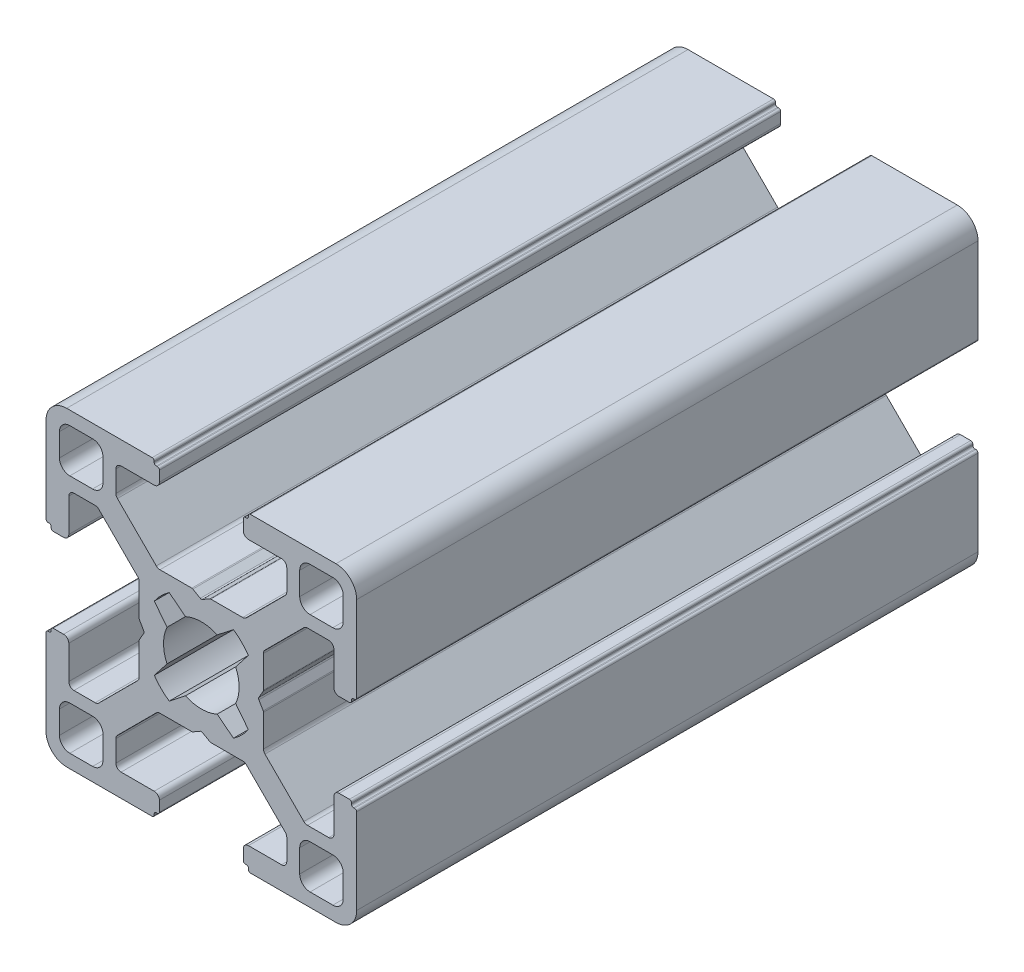
from build123d import *

# Parameters (mm, degrees)
EXTRUDE_1_DEPTH = 60


with BuildPart() as part:
    # Эскиз1 → Бобышка-Вытянуть1 (new body)
    with BuildSketch(Plane.XY):
        with BuildLine():
            Line((-5.557735027, 0.1), (-5.973205081, 0.819615242))
            ThreePointArc((-5.973205081, 0.819615242), (-5.993185165, 0.867851433), (-6, 0.919615242))
            Line((-6, 0.919615242), (-6, 3.996841995))
            ThreePointArc((-6, 3.996841995), (-6.038060234, 4.188183711), (-6.146446609, 4.350395385))
            Line((-6.146446609, 4.350395385), (-9.899604615, 8.103553391))
            ThreePointArc((-9.899604615, 8.103553391), (-10.061816289, 8.211939766), (-10.253158005, 8.25))
            Line((-10.253158005, 8.25), (-12.3, 8.25))
            ThreePointArc((-12.3, 8.25), (-12.653553391, 8.103553391), (-12.8, 7.75))
            Line((-12.8, 7.75), (-12.8, 4.55))
            ThreePointArc((-12.8, 4.55), (-12.946446609, 4.196446609), (-13.3, 4.05))
            Line((-13.3, 4.05), (-14.3, 4.05))
            ThreePointArc((-14.3, 4.05), (-14.441421356, 4.108578644), (-14.5, 4.25))
            Line((-14.5, 4.25), (-14.5, 4.35))
            ThreePointArc((-14.5, 4.35), (-14.558578644, 4.491421356), (-14.7, 4.55))
            Line((-14.7, 4.55), (-14.8, 4.55))
            ThreePointArc((-14.8, 4.55), (-14.941421356, 4.608578644), (-15, 4.75))
            Line((-15, 4.75), (-15, 13))
            ThreePointArc((-15, 13), (-14.414213562, 14.414213562), (-13, 15))
            Line((-13, 15), (-4.75, 15))
            ThreePointArc((-4.75, 15), (-4.608578644, 14.941421356), (-4.55, 14.8))
            Line((-4.55, 14.8), (-4.55, 14.7))
            ThreePointArc((-4.55, 14.7), (-4.491421356, 14.558578644), (-4.35, 14.5))
            Line((-4.35, 14.5), (-4.25, 14.5))
            ThreePointArc((-4.25, 14.5), (-4.108578644, 14.441421356), (-4.05, 14.3))
            Line((-4.05, 14.3), (-4.05, 13.3))
            ThreePointArc((-4.05, 13.3), (-4.196446609, 12.946446609), (-4.55, 12.8))
            Line((-4.55, 12.8), (-7.75, 12.8))
            ThreePointArc((-7.75, 12.8), (-8.103553391, 12.653553391), (-8.25, 12.3))
            Line((-8.25, 12.3), (-8.25, 10.253158005))
            ThreePointArc((-8.25, 10.253158005), (-8.211939766, 10.061816289), (-8.103553391, 9.899604615))
            Line((-8.103553391, 9.899604615), (-4.350395385, 6.146446609))
            ThreePointArc((-4.350395385, 6.146446609), (-4.188183711, 6.038060234), (-3.996841995, 6))
            Line((-3.996841995, 6), (-0.919615242, 6))
            ThreePointArc((-0.919615242, 6), (-0.867851433, 5.993185165), (-0.819615242, 5.973205081))
            Line((-0.819615242, 5.973205081), (-0.1, 5.557735027))
            ThreePointArc((-0.1, 5.557735027), (0, 5.530940108), (0.1, 5.557735027))
            Line((0.1, 5.557735027), (0.819615242, 5.973205081))
            ThreePointArc((0.819615242, 5.973205081), (0.867851433, 5.993185165), (0.919615242, 6))
            Line((0.919615242, 6), (3.996841995, 6))
            ThreePointArc((3.996841995, 6), (4.188183711, 6.038060234), (4.350395385, 6.146446609))
            Line((4.350395385, 6.146446609), (8.103553391, 9.899604615))
            ThreePointArc((8.103553391, 9.899604615), (8.211939766, 10.061816289), (8.25, 10.253158005))
            Line((8.25, 10.253158005), (8.25, 12.3))
            ThreePointArc((8.25, 12.3), (8.103553391, 12.653553391), (7.75, 12.8))
            Line((7.75, 12.8), (4.55, 12.8))
            ThreePointArc((4.55, 12.8), (4.196446609, 12.946446609), (4.05, 13.3))
            Line((4.05, 13.3), (4.05, 14.3))
            ThreePointArc((4.05, 14.3), (4.108578644, 14.441421356), (4.25, 14.5))
            Line((4.25, 14.5), (4.35, 14.5))
            ThreePointArc((4.35, 14.5), (4.491421356, 14.558578644), (4.55, 14.7))
            Line((4.55, 14.7), (4.55, 14.8))
            ThreePointArc((4.55, 14.8), (4.608578644, 14.941421356), (4.75, 15))
            Line((4.75, 15), (13, 15))
            ThreePointArc((13, 15), (14.414213562, 14.414213562), (15, 13))
            Line((15, 13), (15, 4.75))
            ThreePointArc((15, 4.75), (14.941421356, 4.608578644), (14.8, 4.55))
            Line((14.8, 4.55), (14.7, 4.55))
            ThreePointArc((14.7, 4.55), (14.558578644, 4.491421356), (14.5, 4.35))
            Line((14.5, 4.35), (14.5, 4.25))
            ThreePointArc((14.5, 4.25), (14.441421356, 4.108578644), (14.3, 4.05))
            Line((14.3, 4.05), (13.3, 4.05))
            ThreePointArc((13.3, 4.05), (12.946446609, 4.196446609), (12.8, 4.55))
            Line((12.8, 4.55), (12.8, 7.75))
            ThreePointArc((12.8, 7.75), (12.653553391, 8.103553391), (12.3, 8.25))
            Line((12.3, 8.25), (10.253158005, 8.25))
            ThreePointArc((10.253158005, 8.25), (10.061816289, 8.211939766), (9.899604615, 8.103553391))
            Line((9.899604615, 8.103553391), (6.146446609, 4.350395385))
            ThreePointArc((6.146446609, 4.350395385), (6.038060234, 4.188183711), (6, 3.996841995))
            Line((6, 3.996841995), (6, 0.919615242))
            ThreePointArc((6, 0.919615242), (5.993185165, 0.867851433), (5.973205081, 0.819615242))
            Line((5.973205081, 0.819615242), (5.557735027, 0.1))
            ThreePointArc((5.557735027, 0.1), (5.530940108, 0), (5.557735027, -0.1))
            Line((5.557735027, -0.1), (5.973205081, -0.819615242))
            ThreePointArc((5.973205081, -0.819615242), (5.993185165, -0.867851433), (6, -0.919615242))
            Line((6, -0.919615242), (6, -3.996841995))
            ThreePointArc((6, -3.996841995), (6.038060234, -4.188183711), (6.146446609, -4.350395385))
            Line((6.146446609, -4.350395385), (9.899604615, -8.103553391))
            ThreePointArc((9.899604615, -8.103553391), (10.061816289, -8.211939766), (10.253158005, -8.25))
            Line((10.253158005, -8.25), (12.3, -8.25))
            ThreePointArc((12.3, -8.25), (12.653553391, -8.103553391), (12.8, -7.75))
            Line((12.8, -7.75), (12.8, -4.55))
            ThreePointArc((12.8, -4.55), (12.946446609, -4.196446609), (13.3, -4.05))
            Line((13.3, -4.05), (14.3, -4.05))
            ThreePointArc((14.3, -4.05), (14.441421356, -4.108578644), (14.5, -4.25))
            Line((14.5, -4.25), (14.5, -4.35))
            ThreePointArc((14.5, -4.35), (14.558578644, -4.491421356), (14.7, -4.55))
            Line((14.7, -4.55), (14.8, -4.55))
            ThreePointArc((14.8, -4.55), (14.941421356, -4.608578644), (15, -4.75))
            Line((15, -4.75), (15, -13))
            ThreePointArc((15, -13), (14.414213562, -14.414213562), (13, -15))
            Line((13, -15), (4.75, -15))
            ThreePointArc((4.75, -15), (4.608578644, -14.941421356), (4.55, -14.8))
            Line((4.55, -14.8), (4.55, -14.7))
            ThreePointArc((4.55, -14.7), (4.491421356, -14.558578644), (4.35, -14.5))
            Line((4.35, -14.5), (4.25, -14.5))
            ThreePointArc((4.25, -14.5), (4.108578644, -14.441421356), (4.05, -14.3))
            Line((4.05, -14.3), (4.05, -13.3))
            ThreePointArc((4.05, -13.3), (4.196446609, -12.946446609), (4.55, -12.8))
            Line((4.55, -12.8), (7.75, -12.8))
            ThreePointArc((7.75, -12.8), (8.103553391, -12.653553391), (8.25, -12.3))
            Line((8.25, -12.3), (8.25, -10.253158005))
            ThreePointArc((8.25, -10.253158005), (8.211939766, -10.061816289), (8.103553391, -9.899604615))
            Line((8.103553391, -9.899604615), (4.350395385, -6.146446609))
            ThreePointArc((4.350395385, -6.146446609), (4.188183711, -6.038060234), (3.996841995, -6))
            Line((3.996841995, -6), (0.919615242, -6))
            ThreePointArc((0.919615242, -6), (0.867851433, -5.993185165), (0.819615242, -5.973205081))
            Line((0.819615242, -5.973205081), (0.1, -5.557735027))
            ThreePointArc((0.1, -5.557735027), (0, -5.530940108), (-0.1, -5.557735027))
            Line((-0.1, -5.557735027), (-0.819615242, -5.973205081))
            ThreePointArc((-0.819615242, -5.973205081), (-0.867851433, -5.993185165), (-0.919615242, -6))
            Line((-0.919615242, -6), (-3.996841995, -6))
            ThreePointArc((-3.996841995, -6), (-4.188183711, -6.038060234), (-4.350395385, -6.146446609))
            Line((-4.350395385, -6.146446609), (-8.103553391, -9.899604615))
            ThreePointArc((-8.103553391, -9.899604615), (-8.211939766, -10.061816289), (-8.25, -10.253158005))
            Line((-8.25, -10.253158005), (-8.25, -12.3))
            ThreePointArc((-8.25, -12.3), (-8.103553391, -12.653553391), (-7.75, -12.8))
            Line((-7.75, -12.8), (-4.55, -12.8))
            ThreePointArc((-4.55, -12.8), (-4.196446609, -12.946446609), (-4.05, -13.3))
            Line((-4.05, -13.3), (-4.05, -14.3))
            ThreePointArc((-4.05, -14.3), (-4.108578644, -14.441421356), (-4.25, -14.5))
            Line((-4.25, -14.5), (-4.35, -14.5))
            ThreePointArc((-4.35, -14.5), (-4.491421356, -14.558578644), (-4.55, -14.7))
            Line((-4.55, -14.7), (-4.55, -14.8))
            ThreePointArc((-4.55, -14.8), (-4.608578644, -14.941421356), (-4.75, -15))
            Line((-4.75, -15), (-13, -15))
            ThreePointArc((-13, -15), (-14.414213562, -14.414213562), (-15, -13))
            Line((-15, -13), (-15, -4.75))
            ThreePointArc((-15, -4.75), (-14.941421356, -4.608578644), (-14.8, -4.55))
            Line((-14.8, -4.55), (-14.7, -4.55))
            ThreePointArc((-14.7, -4.55), (-14.558578644, -4.491421356), (-14.5, -4.35))
            Line((-14.5, -4.35), (-14.5, -4.25))
            ThreePointArc((-14.5, -4.25), (-14.441421356, -4.108578644), (-14.3, -4.05))
            Line((-14.3, -4.05), (-13.3, -4.05))
            ThreePointArc((-13.3, -4.05), (-12.946446609, -4.196446609), (-12.8, -4.55))
            Line((-12.8, -4.55), (-12.8, -7.75))
            ThreePointArc((-12.8, -7.75), (-12.653553391, -8.103553391), (-12.3, -8.25))
            Line((-12.3, -8.25), (-10.253158005, -8.25))
            ThreePointArc((-10.253158005, -8.25), (-10.061816289, -8.211939766), (-9.899604615, -8.103553391))
            Line((-9.899604615, -8.103553391), (-6.146446609, -4.350395385))
            ThreePointArc((-6.146446609, -4.350395385), (-6.038060234, -4.188183711), (-6, -3.996841995))
            Line((-6, -3.996841995), (-6, -0.919615242))
            ThreePointArc((-6, -0.919615242), (-5.993185165, -0.867851433), (-5.973205081, -0.819615242))
            Line((-5.973205081, -0.819615242), (-5.557735027, -0.1))
            ThreePointArc((-5.557735027, -0.1), (-5.530940108, 0), (-5.557735027, 0.1))
        make_face()
        with BuildLine():
            Line((-4.54098589, 3.103135052), (-3.313131952, 1.531553678))
            ThreePointArc((-3.313131952, 1.531553678), (-3.65, 0), (-3.313131952, -1.531553678))
            Line((-3.313131952, -1.531553678), (-4.54098589, -3.103135052))
            ThreePointArc((-4.54098589, -3.103135052), (-3.889087297, -3.889087297), (-3.103135052, -4.54098589))
            Line((-3.103135052, -4.54098589), (-1.531553678, -3.313131952))
            ThreePointArc((-1.531553678, -3.313131952), (0, -3.65), (1.531553678, -3.313131952))
            Line((1.531553678, -3.313131952), (3.103135052, -4.54098589))
            ThreePointArc((3.103135052, -4.54098589), (3.889087297, -3.889087297), (4.54098589, -3.103135052))
            Line((4.54098589, -3.103135052), (3.313131952, -1.531553678))
            ThreePointArc((3.313131952, -1.531553678), (3.65, 0), (3.313131952, 1.531553678))
            Line((3.313131952, 1.531553678), (4.54098589, 3.103135052))
            ThreePointArc((4.54098589, 3.103135052), (3.889087297, 3.889087297), (3.103135052, 4.54098589))
            Line((3.103135052, 4.54098589), (1.531553678, 3.313131952))
            ThreePointArc((1.531553678, 3.313131952), (0, 3.65), (-1.531553678, 3.313131952))
            Line((-1.531553678, 3.313131952), (-3.103135052, 4.54098589))
            ThreePointArc((-3.103135052, 4.54098589), (-3.889087297, 3.889087297), (-4.54098589, 3.103135052))
        make_face(mode=Mode.SUBTRACT)
        with BuildLine():
            Line((-13.7, 12.7), (-13.7, 10.5))
            ThreePointArc((-13.7, 10.5), (-13.407106781, 9.792893219), (-12.7, 9.5))
            Line((-12.7, 9.5), (-10.5, 9.5))
            ThreePointArc((-10.5, 9.5), (-9.792893219, 9.792893219), (-9.5, 10.5))
            Line((-9.5, 10.5), (-9.5, 12.7))
            ThreePointArc((-9.5, 12.7), (-9.792893219, 13.407106781), (-10.5, 13.7))
            Line((-10.5, 13.7), (-12.7, 13.7))
            ThreePointArc((-12.7, 13.7), (-13.407106781, 13.407106781), (-13.7, 12.7))
        make_face(mode=Mode.SUBTRACT)
        with BuildLine():
            Line((-9.5, -10.5), (-9.5, -12.7))
            ThreePointArc((-9.5, -12.7), (-9.792893219, -13.407106781), (-10.5, -13.7))
            Line((-10.5, -13.7), (-12.7, -13.7))
            ThreePointArc((-12.7, -13.7), (-13.407106781, -13.407106781), (-13.7, -12.7))
            Line((-13.7, -12.7), (-13.7, -10.5))
            ThreePointArc((-13.7, -10.5), (-13.407106781, -9.792893219), (-12.7, -9.5))
            Line((-12.7, -9.5), (-10.5, -9.5))
            ThreePointArc((-10.5, -9.5), (-9.792893219, -9.792893219), (-9.5, -10.5))
        make_face(mode=Mode.SUBTRACT)
        with BuildLine():
            Line((13.7, -12.7), (13.7, -10.5))
            ThreePointArc((13.7, -10.5), (13.407106781, -9.792893219), (12.7, -9.5))
            Line((12.7, -9.5), (10.5, -9.5))
            ThreePointArc((10.5, -9.5), (9.792893219, -9.792893219), (9.5, -10.5))
            Line((9.5, -10.5), (9.5, -12.7))
            ThreePointArc((9.5, -12.7), (9.792893219, -13.407106781), (10.5, -13.7))
            Line((10.5, -13.7), (12.7, -13.7))
            ThreePointArc((12.7, -13.7), (13.407106781, -13.407106781), (13.7, -12.7))
        make_face(mode=Mode.SUBTRACT)
        with BuildLine():
            Line((9.5, 10.5), (9.5, 12.7))
            ThreePointArc((9.5, 12.7), (9.792893219, 13.407106781), (10.5, 13.7))
            Line((10.5, 13.7), (12.7, 13.7))
            ThreePointArc((12.7, 13.7), (13.407106781, 13.407106781), (13.7, 12.7))
            Line((13.7, 12.7), (13.7, 10.5))
            ThreePointArc((13.7, 10.5), (13.407106781, 9.792893219), (12.7, 9.5))
            Line((12.7, 9.5), (10.5, 9.5))
            ThreePointArc((10.5, 9.5), (9.792893219, 9.792893219), (9.5, 10.5))
        make_face(mode=Mode.SUBTRACT)
    extrude(amount=EXTRUDE_1_DEPTH)


solid = part.part
